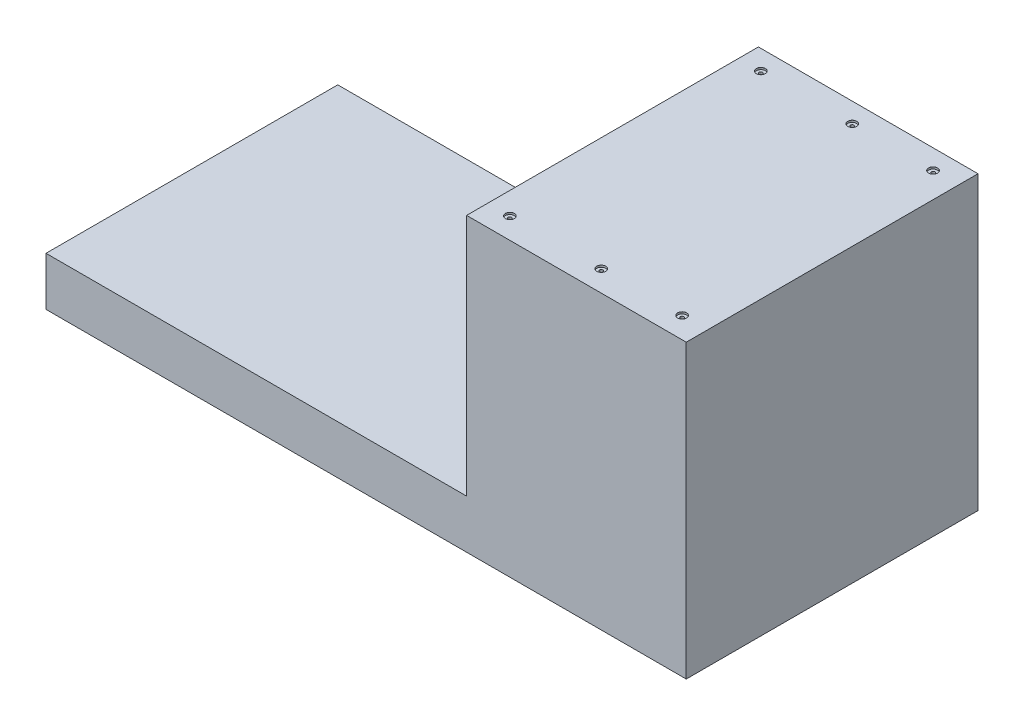
from build123d import *

# Parameters (mm, degrees)
SKETCH1_W                                   = 508
SKETCH1_H                                   = 304.8
BOSS_EXTRUDE1_DEPTH                         = 50.8
SKETCH2_W                                   = 229.423241107
SKETCH2_H                                   = 304.8
BOSS_EXTRUDE2_DEPTH                         = 254
BOSS_EXTRUDE3_DEPTH                         = 304.8
CBORE_FOR_M3_HEX_HEAD_CAP_SCREW1_AT_2_COUNT = 2
CBORE_FOR_M3_HEX_HEAD_CAP_SCREW1_AT_2_PITCH = 95.46630017
CBORE_FOR_M3_HEX_HEAD_CAP_SCREW1_AT_3_COUNT = 2
CBORE_FOR_M3_HEX_HEAD_CAP_SCREW1_AT_3_PITCH = 179.917258012
CBORE_FOR_M3_HEX_HEAD_CAP_SCREW1_AT_4_COUNT = 2
CBORE_FOR_M3_HEX_HEAD_CAP_SCREW1_AT_4_PITCH = 317.963495132
CBORE_FOR_M3_HEX_HEAD_CAP_SCREW1_AT_5_COUNT = 2
CBORE_FOR_M3_HEX_HEAD_CAP_SCREW1_AT_5_PITCH = 279.006055443
CBORE_FOR_M3_HEX_HEAD_CAP_SCREW1_AT_6_COUNT = 2
CBORE_FOR_M3_HEX_HEAD_CAP_SCREW1_AT_6_PITCH = 262.165147389


with BuildPart() as part:
    # Sketch1 → Boss-Extrude1 (new body)
    with BuildSketch(Plane(origin=(0, 0, 0), x_dir=(1, 0, 0), z_dir=(0, 1, 0))):
        Rectangle(SKETCH1_W, SKETCH1_H)
    extrude(amount=BOSS_EXTRUDE1_DEPTH)

    # Sketch2 → Boss-Extrude2 (add)
    with BuildSketch(Plane(origin=(0, 50.8, 0), x_dir=(1, 0, 0), z_dir=(0, 1, 0))):
        with Locations((139.288379447, 0)):
            Rectangle(SKETCH2_W, SKETCH2_H)
    extrude(amount=BOSS_EXTRUDE2_DEPTH)

    # Sketch3 → Boss-Extrude3 (add)
    with BuildSketch(Plane.XY.offset(152.4)):
        Polygon((-254, 0), (-414.851586113, 0), (-414.851586113, 50.8), (-254, 50.8), (24.576758893, 50.8), (24.576758893, 304.8), (254, 304.8), (254, 0), align=None)
    extrude(amount=-BOSS_EXTRUDE3_DEPTH)

    # Sketch6 → CBORE for M3 Hex Head Cap Screw1 (revolve, cut)
    with BuildSketch(Plane(origin=(47.719356018, 304.8, -131.81692985), x_dir=(0, 0, 1), z_dir=(1, 0, 0))):
        Polygon((0, 0), (0, 304.8), (1.8, 304.8), (1.8, 2), (4.6755, 2), (4.6755, 0.025), (4.7005, 0), align=None)
    cbore_for_m3_hex_head_cap_screw1 = revolve(axis=Axis((47.719356018, 311.15, -131.81692985), (0, -1, 0)), mode=Mode.SUBTRACT)

    # CBORE for M3 Hex Head Cap Screw1 at 2: CBORE for M3 Hex Head Cap Screw1 ×2
    with Locations(*[(i * CBORE_FOR_M3_HEX_HEAD_CAP_SCREW1_AT_2_PITCH, 0, 0) for i in range(1, CBORE_FOR_M3_HEX_HEAD_CAP_SCREW1_AT_2_COUNT)]):
        add(cbore_for_m3_hex_head_cap_screw1, mode=Mode.SUBTRACT)

    # CBORE for M3 Hex Head Cap Screw1 at 3: CBORE for M3 Hex Head Cap Screw1 ×2
    with Locations(*[(i * CBORE_FOR_M3_HEX_HEAD_CAP_SCREW1_AT_3_PITCH, 0, 0) for i in range(1, CBORE_FOR_M3_HEX_HEAD_CAP_SCREW1_AT_3_COUNT)]):
        add(cbore_for_m3_hex_head_cap_screw1, mode=Mode.SUBTRACT)

    # CBORE for M3 Hex Head Cap Screw1 at 4: CBORE for M3 Hex Head Cap Screw1 ×2
    with Locations(*[Vector(0.565842497, 0, 0.824513353) * (i * CBORE_FOR_M3_HEX_HEAD_CAP_SCREW1_AT_4_PITCH) for i in range(1, CBORE_FOR_M3_HEX_HEAD_CAP_SCREW1_AT_4_COUNT)]):
        add(cbore_for_m3_hex_head_cap_screw1, mode=Mode.SUBTRACT)

    # CBORE for M3 Hex Head Cap Screw1 at 5: CBORE for M3 Hex Head Cap Screw1 ×2
    with Locations(*[Vector(0.342165692, 0, 0.939639632) * (i * CBORE_FOR_M3_HEX_HEAD_CAP_SCREW1_AT_5_PITCH) for i in range(1, CBORE_FOR_M3_HEX_HEAD_CAP_SCREW1_AT_5_COUNT)]):
        add(cbore_for_m3_hex_head_cap_screw1, mode=Mode.SUBTRACT)

    # CBORE for M3 Hex Head Cap Screw1 at 6: CBORE for M3 Hex Head Cap Screw1 ×2
    with Locations(*[(0, 0, i * CBORE_FOR_M3_HEX_HEAD_CAP_SCREW1_AT_6_PITCH) for i in range(1, CBORE_FOR_M3_HEX_HEAD_CAP_SCREW1_AT_6_COUNT)]):
        add(cbore_for_m3_hex_head_cap_screw1, mode=Mode.SUBTRACT)


solid = part.part
